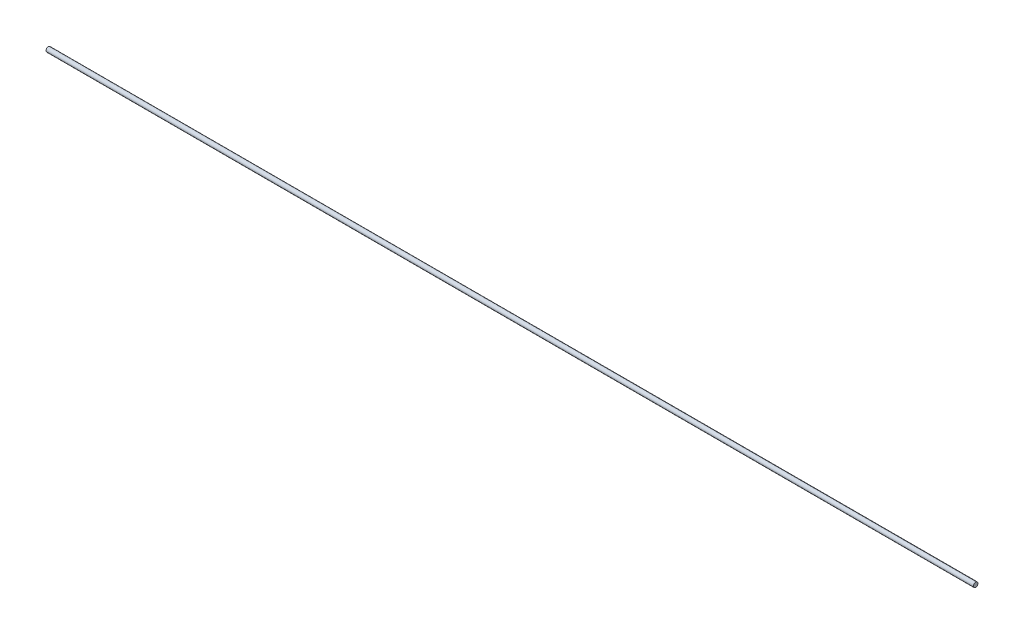
from build123d import *

# Parameters (mm, degrees)
SKETCH1_R           = 2.5
BOSS_EXTRUDE1_DEPTH = 1000


with BuildPart() as part:
    # Sketch1 → Boss-Extrude1 (new body)
    with BuildSketch(Plane(origin=(0, 0, 0), x_dir=(0, 0, -1), z_dir=(1, 0, 0))):
        Circle(SKETCH1_R)
    extrude(amount=BOSS_EXTRUDE1_DEPTH)


solid = part.part
